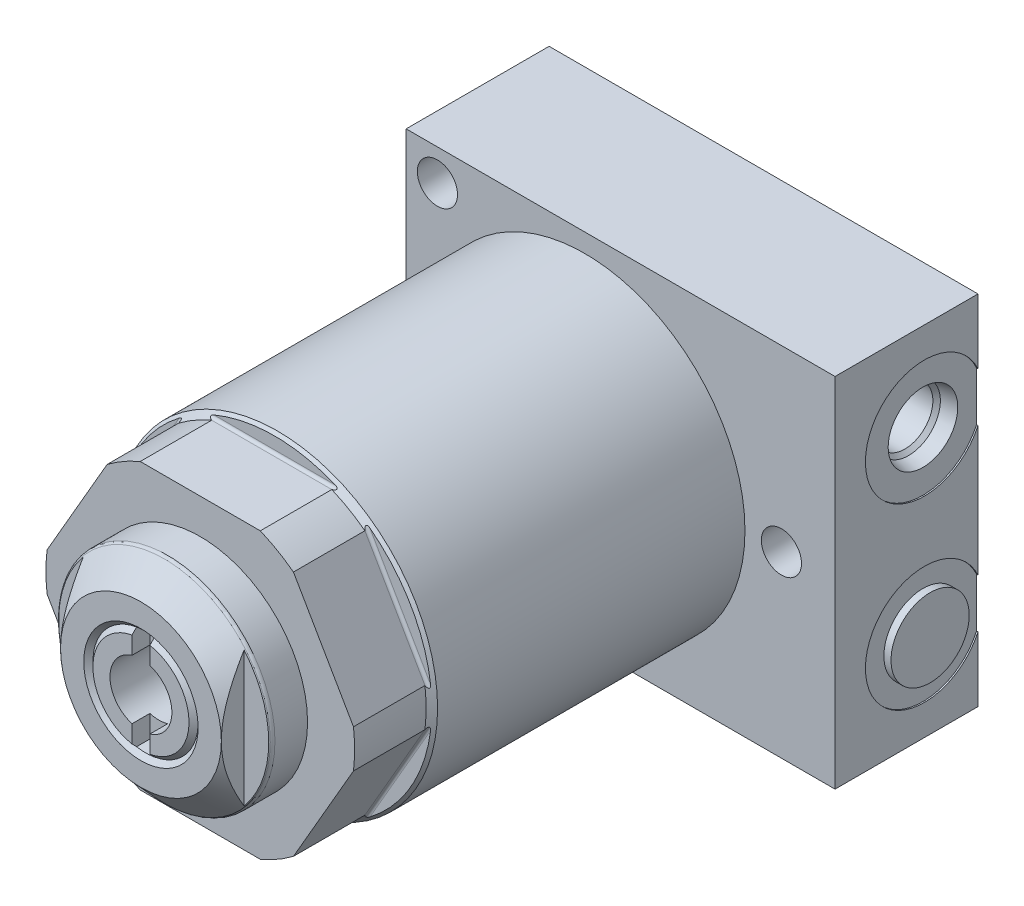
from build123d import *

# Parameters (mm, degrees)
SKETCH1_R           = 28.448
EXTRUDE1_DEPTH      = 82.55
CUT_EXTRUDE1_DEPTH  = 34.1376
SKETCH13_W          = 10.541
SKETCH13_H          = 19.0627
S2D0011_W           = 5.4991
S2D0011_H           = 16.002
SKETCH16_W          = 76.2
SKETCH16_H          = 25.4
EXTRUDE2_DEPTH      = 31.75
EXTRUDE2_DEPTH_BACK = 31.75
SKETCH17_R          = 10.4775
CUT_EXTRUDE9_DEPTH  = 0.254
SKETCH18_R          = 10.4775
CUT_EXTRUDE10_DEPTH = 0.254
SKETCH21_R          = 6.9469
EXTRUDE3_DEPTH      = 1.27
CIRPATTERN2_COUNT   = 6
HOLE1_D             = 7.1374
HOLE1_DEPTH         = 25.4
CUT_EXTRUDE11_DEPTH = 3.175
CUT_EXTRUDE12_DEPTH = 4.0386


with BuildPart() as part:
    # Sketch1 → Extrude1 (new body)
    with BuildSketch(Plane.XY):
        Circle(SKETCH1_R)
    extrude(amount=EXTRUDE1_DEPTH)

    # Sketch2 → Cut-Extrude1 (cut, symmetric)
    with BuildSketch(Plane(origin=(0, 0, 0), x_dir=(0, 0, 1), z_dir=(1, 0, 0))):
        with BuildLine():
            Line((69.342, 28.448), (69.342, 25.781))
            ThreePointArc((69.342, 25.781), (69.490789755, 25.421789755), (69.85, 25.273))
            Line((69.85, 25.273), (82.55, 25.273))
            Line((82.55, 25.273), (82.55, 28.448))
            Line((82.55, 28.448), (69.342, 28.448))
        make_face()
    cut_extrude1 = extrude(amount=CUT_EXTRUDE1_DEPTH, both=True, mode=Mode.SUBTRACT)

    # Sketch10 → Cut-Revolve1 (revolve, cut)
    with BuildSketch(Plane(origin=(0, 0, 0), x_dir=(0, 0, -1), z_dir=(1, 0, 0)), mode=Mode.PRIVATE) as cut_revolve1_sk:
        Polygon((-82.55, 27.432), (-69.85, 27.432), (-68.834, 28.448), (-82.55, 28.448), align=None)
    revolve(cut_revolve1_sk.sketch.rotate(Axis((0, 0, 83.2358), (0, 0, -1)), 90), axis=Axis((0, 0, 83.2358), (0, 0, -1)), mode=Mode.SUBTRACT)  # turned: the seam where the file's is

    # Sketch13 → Revolve1 (revolve)
    with BuildSketch(Plane(origin=(0, 0, 0), x_dir=(0, 0, -1), z_dir=(1, 0, 0)), mode=Mode.PRIVATE) as revolve1_sk:
        with Locations((-87.8205, 9.53135)):
            Rectangle(SKETCH13_W, SKETCH13_H)
    revolve(revolve1_sk.sketch.rotate(Axis((0, 0, 93.61805), (0, 0, -1)), 90), axis=Axis((0, 0, 93.61805), (0, 0, -1)))  # turned: the seam where the file's is

    # S2D0011 → Cut-Revolve4 (revolve, cut)
    with BuildSketch(Plane(origin=(-5.4991, 0, 93.091), x_dir=(-1, 0, 0), z_dir=(0, 1, 0)), mode=Mode.PRIVATE) as cut_revolve4_sk:
        with Locations((-2.74955, -8.001)):
            Rectangle(S2D0011_W, S2D0011_H)
    revolve(cut_revolve4_sk.sketch.rotate(Axis((0, 0, 56.25285781), (0, 0, 1)), 180), axis=Axis((0, 0, 56.25285781), (0, 0, 1)), mode=Mode.SUBTRACT)  # turned: the seam where the file's is

    # Sketch15 → Cut-Revolve5 (revolve, cut)
    with BuildSketch(Plane(origin=(0, 0, 0), x_dir=(0, 0, -1), z_dir=(1, 0, 0)), mode=Mode.PRIVATE) as cut_revolve5_sk:
        with BuildLine():
            Line((-93.091, 14.2875), (-88.919964429, 18.809182473))
            ThreePointArc((-88.919964429, 18.809182473), (-88.65712697, 18.996541229), (-88.3412, 19.0627))
            Line((-88.3412, 19.0627), (-93.091, 19.0627))
            Line((-93.091, 19.0627), (-93.091, 14.2875))
        make_face()
    revolve(cut_revolve5_sk.sketch.rotate(Axis((0, 0, 93.32849), (0, 0, -1)), 90), axis=Axis((0, 0, 93.32849), (0, 0, -1)), mode=Mode.SUBTRACT)  # turned: the seam where the file's is

    # Sketch16 → Extrude2 (add, two sides)
    with BuildSketch(Plane(origin=(0, 0, 0), x_dir=(-1, 0, 0), z_dir=(0, 1, 0))) as extrude2_sk:
        with Locations((-6.35, 1.524)):
            Rectangle(SKETCH16_W, SKETCH16_H)
    extrude(amount=EXTRUDE2_DEPTH)
    extrude(extrude2_sk.sketch, amount=-EXTRUDE2_DEPTH_BACK)

    # Sketch17 → Cut-Extrude9 (cut)
    with BuildSketch(Plane(origin=(44.45, 0, 0), x_dir=(0, 0, -1), z_dir=(1, 0, 0))):
        with Locations((1.651, -15.875)):
            Circle(SKETCH17_R)
    extrude(amount=-CUT_EXTRUDE9_DEPTH, mode=Mode.SUBTRACT)

    # Sketch18 → Cut-Extrude10 (cut)
    with BuildSketch(Plane(origin=(44.45, 0, 0), x_dir=(0, 0, -1), z_dir=(1, 0, 0))):
        with Locations((1.651, 15.875)):
            Circle(SKETCH18_R)
    extrude(amount=-CUT_EXTRUDE10_DEPTH, mode=Mode.SUBTRACT)

    # S2D0002 → Cut-Revolve6 (revolve, cut)
    with BuildSketch(Plane(origin=(44.196, -15.875, -1.651), x_dir=(0, -1, 0), z_dir=(0, 0, 1)), mode=Mode.PRIVATE) as cut_revolve6_sk:
        Polygon((0, 0), (6.1849, 0), (5.642306865, -2.5527), (4.9784, -3.216606865), (4.9784, -17.272), (0, -17.272), align=None)
    revolve(cut_revolve6_sk.sketch.rotate(Axis((26.0604, -15.875, -1.651), (1, 0, 0)), 270), axis=Axis((26.0604, -15.875, -1.651), (1, 0, 0)), mode=Mode.SUBTRACT)  # turned: the seam where the file's is

    # S2D0001 → Cut-Revolve7 (revolve, cut)
    with BuildSketch(Plane(origin=(44.196, 15.875, -1.651), x_dir=(0, -1, 0), z_dir=(0, 0, 1)), mode=Mode.PRIVATE) as cut_revolve7_sk:
        Polygon((0, 0), (6.1849, 0), (5.642306865, -2.5527), (4.9784, -3.216606865), (4.9784, -17.272), (0, -17.272), align=None)
    revolve(cut_revolve7_sk.sketch.rotate(Axis((26.0604, 15.875, -1.651), (1, 0, 0)), 270), axis=Axis((26.0604, 15.875, -1.651), (1, 0, 0)), mode=Mode.SUBTRACT)  # turned: the seam where the file's is

    # Sketch21 → Extrude3 (add)
    with BuildSketch(Plane(origin=(44.196, 0, 0), x_dir=(0, 0, -1), z_dir=(1, 0, 0))):
        with Locations((1.651, -15.875)):
            Circle(SKETCH21_R)
    extrude(amount=EXTRUDE3_DEPTH)

    # CirPattern2: Cut-Extrude1 ×6 about axis
    cirpattern2_axis = Axis((0, 0, 0), (0, 0, 1))
    for i in range(1, CIRPATTERN2_COUNT):
        add(cut_extrude1.rotate(cirpattern2_axis, i * 360 / CIRPATTERN2_COUNT), mode=Mode.SUBTRACT)

    # Hole1
    with Locations(Plane.XY.offset(14.224)):
        with Locations((-26.1874, -26.1874), (34.925, 0), (-26.1874, 26.1874)):
            Hole(HOLE1_D / 2, depth=HOLE1_DEPTH)

    # Sketch24 → Cut-Revolve8 (revolve, cut)
    with BuildSketch(Plane(origin=(0, 0, 0), x_dir=(0, 0, -1), z_dir=(1, 0, 0)), mode=Mode.PRIVATE) as cut_revolve8_sk:
        Polygon((-93.091, 8.5344), (-92.2782, 9.3472), (-93.091, 10.16), align=None)
    revolve(cut_revolve8_sk.sketch.rotate(Axis((0, 0, 93.13164), (0, 0, -1)), 90), axis=Axis((0, 0, 93.13164), (0, 0, -1)), mode=Mode.SUBTRACT)  # turned: the seam where the file's is

    # Sketch25 → Cut-Extrude11 (cut)
    with BuildSketch(Plane.XY.offset(93.091)):
        with BuildLine():
            Line((-1.5875, 9.211405517), (-1.5875, -9.211405517))
            ThreePointArc((-1.5875, -9.211405517), (0, -9.3472), (1.5875, -9.211405517))
            Line((1.5875, -9.211405517), (1.5875, 9.211405517))
            ThreePointArc((1.5875, 9.211405517), (0, 9.3472), (-1.5875, 9.211405517))
        make_face()
    extrude(amount=-CUT_EXTRUDE11_DEPTH, mode=Mode.SUBTRACT)

    # Sketch26 → Cut-Extrude12 (cut)
    with BuildSketch(Plane.XY.offset(93.091)):
        with BuildLine():
            Line((-14.2875, 12.619582998), (-14.2875, -12.619582998))
            ThreePointArc((-14.2875, -12.619582998), (-19.0627, 0), (-14.2875, 12.619582998))
        make_face()
        with BuildLine():
            Line((14.2875, 12.619582998), (14.2875, -12.619582998))
            ThreePointArc((14.2875, -12.619582998), (19.0627, 0), (14.2875, 12.619582998))
        make_face()
    extrude(amount=-CUT_EXTRUDE12_DEPTH, mode=Mode.SUBTRACT)


solid = part.part
